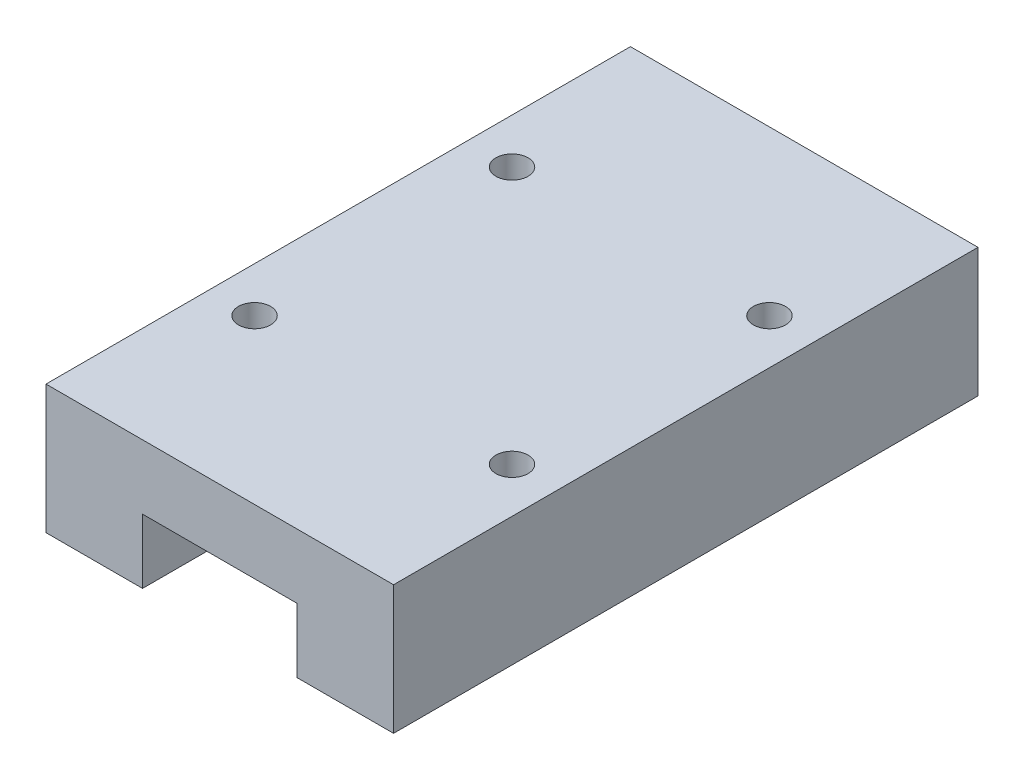
from build123d import *

# Parameters (mm, degrees)
BOSS_EXTRUDE1_DEPTH       = 45.4
M3X0_5_TAPPED_HOLE1_D     = 2.5
M3X0_5_TAPPED_HOLE1_DEPTH = 6
M3X0_5_TAPPED_HOLE1_TIP   = 0.751075774


with BuildPart() as part:
    # Sketch2 → Boss-Extrude1 (new body)
    with BuildSketch(Plane.XY):
        Polygon((0, 0), (0, 10), (27, 10), (27, 0), (19.5, 0), (19.5, 5), (7.5, 5), (7.5, 0), align=None)
    extrude(amount=BOSS_EXTRUDE1_DEPTH)

    # M3x0.5 Tapped Hole1
    with Locations(Plane(origin=(0, 10, 0), x_dir=(1, 0, 0), z_dir=(0, 1, 0))):
        with Locations((23.5, -12.7), (3.5, -12.7), (3.5, -32.7), (23.5, -32.7)):
            Hole(M3X0_5_TAPPED_HOLE1_D / 2, depth=M3X0_5_TAPPED_HOLE1_DEPTH)
            with Locations((0, 0, -(M3X0_5_TAPPED_HOLE1_DEPTH + M3X0_5_TAPPED_HOLE1_TIP / 2))):  # 118° drill point
                Cone(0, M3X0_5_TAPPED_HOLE1_D / 2, M3X0_5_TAPPED_HOLE1_TIP, mode=Mode.SUBTRACT)


solid = part.part
